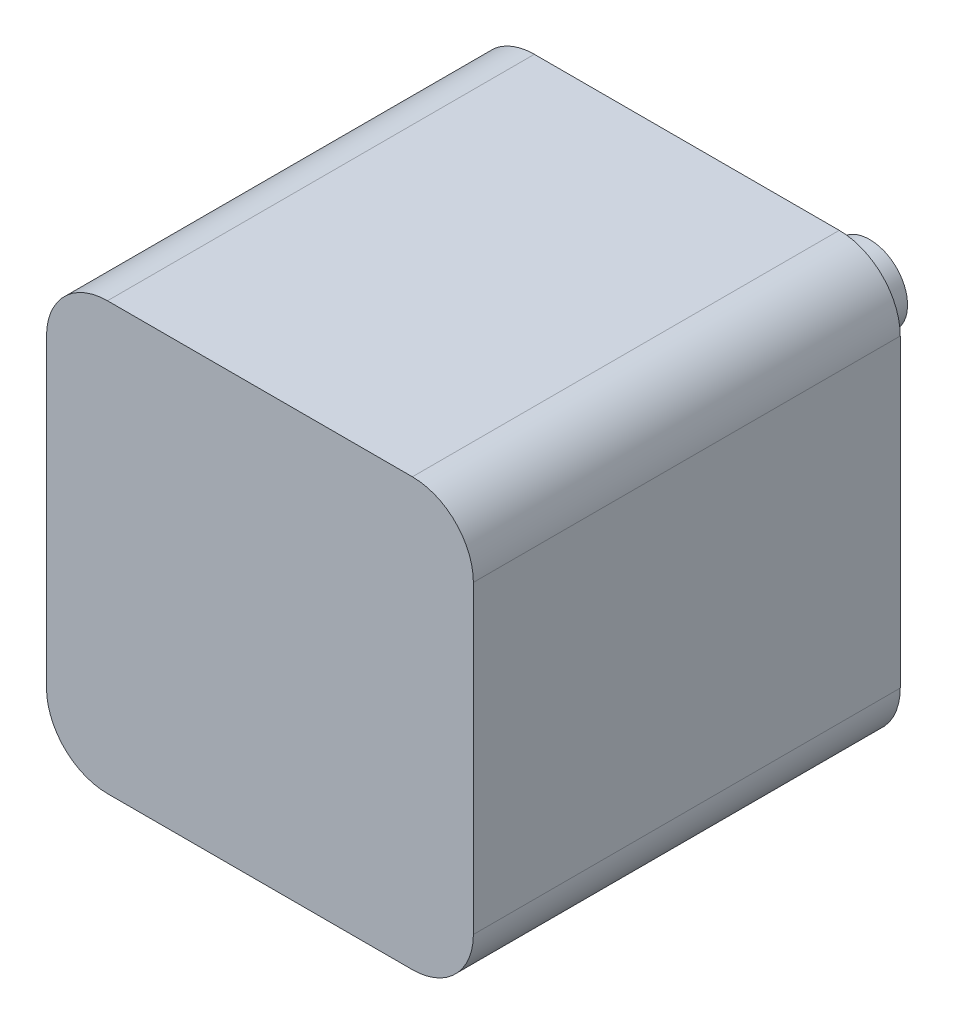
from build123d import *

# Parameters (mm, degrees)
SKETCH1_W           = 17.78
SKETCH1_H           = 17.78
BOSS_EXTRUDE1_DEPTH = 17.78
FILLET1_R           = 2.54
SKETCH2_R           = 1.574444288
BOSS_EXTRUDE2_DEPTH = 7.62


with BuildPart() as part:
    # Sketch1 → Boss-Extrude1 (new body)
    with BuildSketch(Plane.XY):
        Rectangle(SKETCH1_W, SKETCH1_H)
    extrude(amount=BOSS_EXTRUDE1_DEPTH)

    # Fillet1
    fillet1_edges = [part.edges().sort_by_distance(p)[0] for p in [
        (8.89, -8.89, 8.89),
        (-8.89, -8.89, 8.89),
        (-8.89, 8.89, 8.89),
        (8.89, 8.89, 8.89),
    ]]
    fillet(fillet1_edges, radius=FILLET1_R)

    # Sketch2 → Boss-Extrude2 (add)
    with BuildSketch(Plane(origin=(0, 0, 0), x_dir=(-1, 0, 0), z_dir=(0, 0, -1))):
        Circle(SKETCH2_R)
    extrude(amount=BOSS_EXTRUDE2_DEPTH)


solid = part.part
